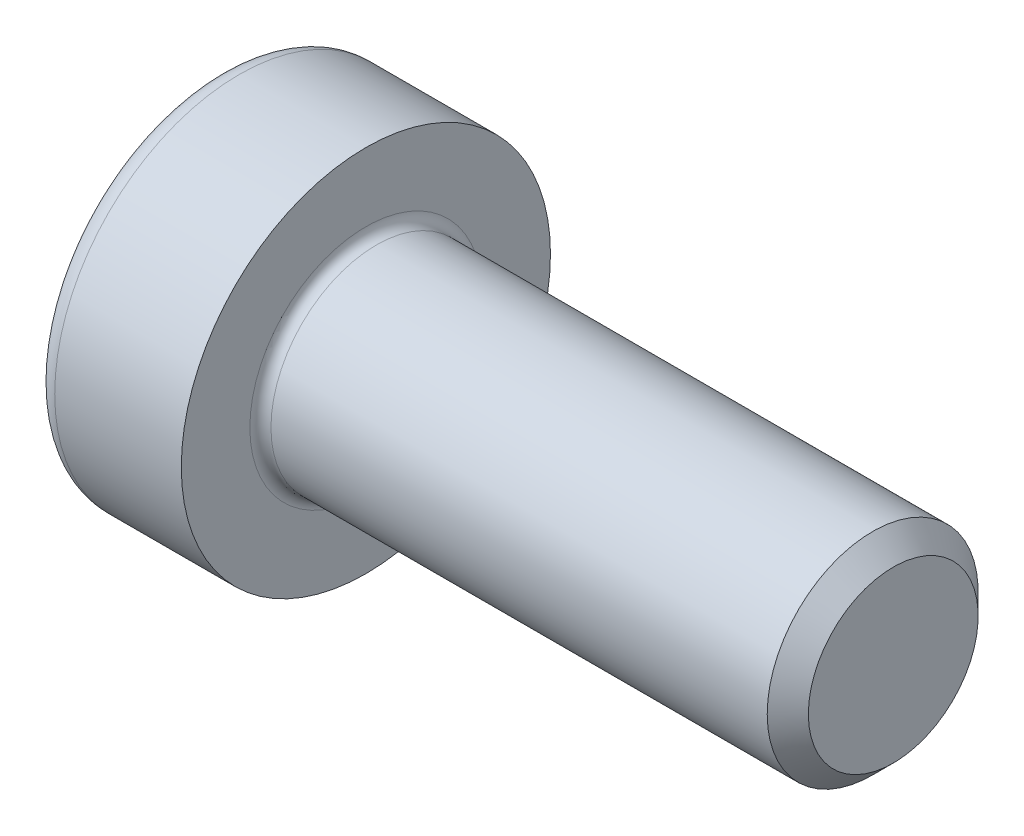
from build123d import *

# Parameters (mm, degrees)
FILLET1_R   = 0.2
FILLET2_R   = 0.4
HEX_2_DEPTH = 1.6


with BuildPart() as part:
    # BodySke → Base-Revolve (revolve)
    with BuildSketch(Plane.XY):
        Polygon((0, 0), (0, 3.5), (2.8, 3.5), (2.8, 2), (12.41, 2), (12.8, 1.61), (12.8, 0), align=None)
    revolve(axis=Axis((-31.75, 0, 0), (1, 0, 0)))

    # Fillet1
    fillet1_edges = [part.edges().sort_by_distance(p)[0] for p in [
        (2.8, -2, 0),
    ]]
    fillet(fillet1_edges, radius=FILLET1_R)

    # Fillet2
    fillet2_edges = [part.edges().sort_by_distance(p)[0] for p in [
        (0, -3.5, 0),
    ]]
    fillet(fillet2_edges, radius=FILLET2_R)

    # HexSke → Hex 2 (cut)
    with BuildSketch(Plane(origin=(0, 0, 0), x_dir=(0, 0.5, 0.866025404), z_dir=(-1, 0, 0))):
        Polygon((0.866025404, 1.5), (-0.866025404, 1.5), (-1.732050808, 0), (-0.866025404, -1.5), (0.866025404, -1.5), (1.732050808, 0), align=None)
    extrude(amount=-HEX_2_DEPTH, mode=Mode.SUBTRACT)

    # PilotSke → Hex-PreBroach (revolve, cut)
    with BuildSketch(Plane.XY):
        Polygon((0, 1.5), (1.6, 1.5), (1.888675135, 1), (3.3, 1), (3.877350269, 0), (0, 0), align=None)
    revolve(axis=Axis((0, 0, 0), (1, 0, 0)), mode=Mode.SUBTRACT)


solid = part.part
